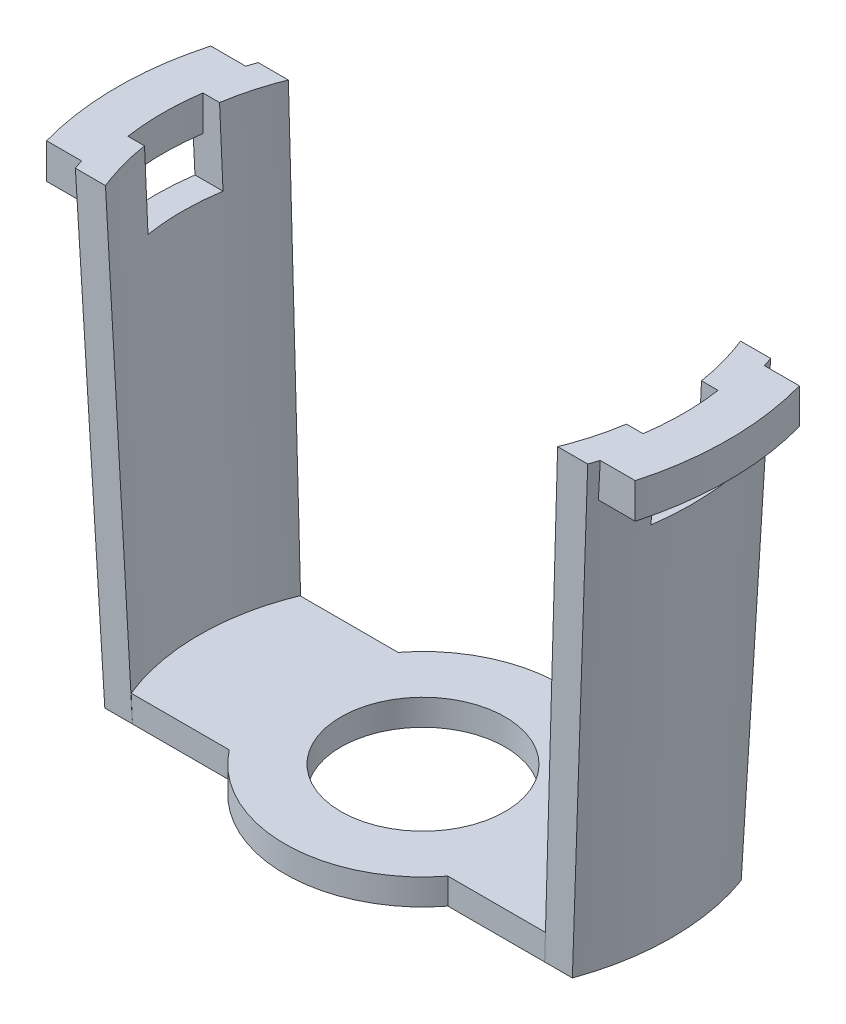
from build123d import *

# Parameters (mm, degrees)
SKETCH1_R                 = 4.445
BASE_DEPTH                = 1.4097
RADIAL_FLANGE_DEPTH       = 1.905
AXIAL_CUT_OUT_DEPTH       = 4.064
SKETCH6_W                 = 4.064
SKETCH6_H                 = 2.159
RADIAL_CUT_OUT_DEPTH      = 17.5481001
RADIAL_CUT_OUT_DEPTH_BACK = 17.5481001


with BuildPart() as part:
    # Sketch1 → Base (new body)
    with BuildSketch(Plane(origin=(0, 0, 0), x_dir=(1, 0, 0), z_dir=(0, 1, 0))):
        with BuildLine():
            Line((-12.661842678, 4.572), (-5.920447964, 4.572))
            ThreePointArc((-5.920447964, 4.572), (0, 7.4803), (5.920447964, 4.572))
            Line((5.920447964, 4.572), (12.661842678, 4.572))
            ThreePointArc((12.661842678, 4.572), (13.462, 0), (12.661842678, -4.572))
            Line((12.661842678, -4.572), (5.920447964, -4.572))
            ThreePointArc((5.920447964, -4.572), (0, -7.4803), (-5.920447964, -4.572))
            Line((-5.920447964, -4.572), (-12.661842678, -4.572))
            ThreePointArc((-12.661842678, -4.572), (-13.462, 0), (-12.661842678, 4.572))
        make_face()
        Circle(SKETCH1_R, mode=Mode.SUBTRACT)
    extrude(amount=BASE_DEPTH)

    # Sketch3 → Arm loft section 0
    with BuildSketch(Plane(origin=(0, 0, 0), x_dir=(1, 0, 0), z_dir=(0, 1, 0))):
        with BuildLine():
            Line((-12.661842678, -4.572), (-11.163242678, -4.572))
            ThreePointArc((-11.163242678, -4.572), (-12.06321562, 0), (-11.163242678, 4.572))
            Line((-11.163242678, 4.572), (-12.661842678, 4.572))
            ThreePointArc((-12.661842678, 4.572), (-13.462, 0), (-12.661842678, -4.572))
        make_face()
    # Sketch2 → Arm loft section 1
    with BuildSketch(Plane(origin=(0, 24.9047, 0), x_dir=(-1, 0, 0), z_dir=(0, -1, 0))):
        with BuildLine():
            Line((12.244143702, 4.953), (13.874423051, 4.953))
            ThreePointArc((13.874423051, 4.953), (14.732, 0), (13.874423051, -4.953))
            Line((13.874423051, -4.953), (12.244143702, -4.953))
            ThreePointArc((12.244143702, -4.953), (13.208, 0), (12.244143702, 4.953))
        make_face()
    arm_loft = loft()

    # Mirror of arm loft: Arm loft across plane
    add(arm_loft.mirror(Plane(origin=(0, 0, 0), x_dir=(0, 0, 1), z_dir=(1, 0, 0))))

    # Sketch4 → Radial flange (add)
    with BuildSketch(Plane(origin=(0, 24.9047, 0), x_dir=(-1, 0, 0), z_dir=(0, -1, 0))):
        with BuildLine():
            Line((12.437573678, 4.445), (15.939936907, 4.445))
            ThreePointArc((15.939936907, 4.445), (16.5481, 0), (15.939936907, -4.445))
            Line((15.939936907, -4.445), (12.437573678, -4.445))
            ThreePointArc((12.437573678, -4.445), (13.208, 0), (12.437573678, 4.445))
        make_face()
    radial_flange = extrude(amount=RADIAL_FLANGE_DEPTH)

    # Sketch5 → Axial cut-out (cut)
    with BuildSketch(Plane(origin=(0, 24.9047, 0), x_dir=(1, 0, 0), z_dir=(0, 1, 0))):
        with BuildLine():
            Line((-11.247927631, 2.032), (-13.949780823, 2.032))
            ThreePointArc((-13.949780823, 2.032), (-14.097, 0), (-13.949780823, -2.032))
            Line((-13.949780823, -2.032), (-11.247927631, -2.032))
            ThreePointArc((-11.247927631, -2.032), (-11.43, 0), (-11.247927631, 2.032))
        make_face()
    axial_cut_out = extrude(amount=-AXIAL_CUT_OUT_DEPTH, mode=Mode.SUBTRACT)

    # Mirror of radial flange and axial cut-out: Radial flange, Axial cut-out across plane
    add(radial_flange.mirror(Plane(origin=(0, 0, 0), x_dir=(0, 0, 1), z_dir=(1, 0, 0))))
    add(axial_cut_out.mirror(Plane(origin=(0, 0, 0), x_dir=(0, 0, 1), z_dir=(1, 0, 0))), mode=Mode.SUBTRACT)

    # Sketch6 → Radial cut-out (cut, two sides)
    with BuildSketch(Plane(origin=(0, 0, 0), x_dir=(0, 0, -1), z_dir=(1, 0, 0))) as radial_cut_out_sk:
        with Locations((0, 21.9202)):
            Rectangle(SKETCH6_W, SKETCH6_H)
    extrude(amount=RADIAL_CUT_OUT_DEPTH, mode=Mode.SUBTRACT)
    extrude(radial_cut_out_sk.sketch, amount=-RADIAL_CUT_OUT_DEPTH_BACK, mode=Mode.SUBTRACT)


solid = part.part
